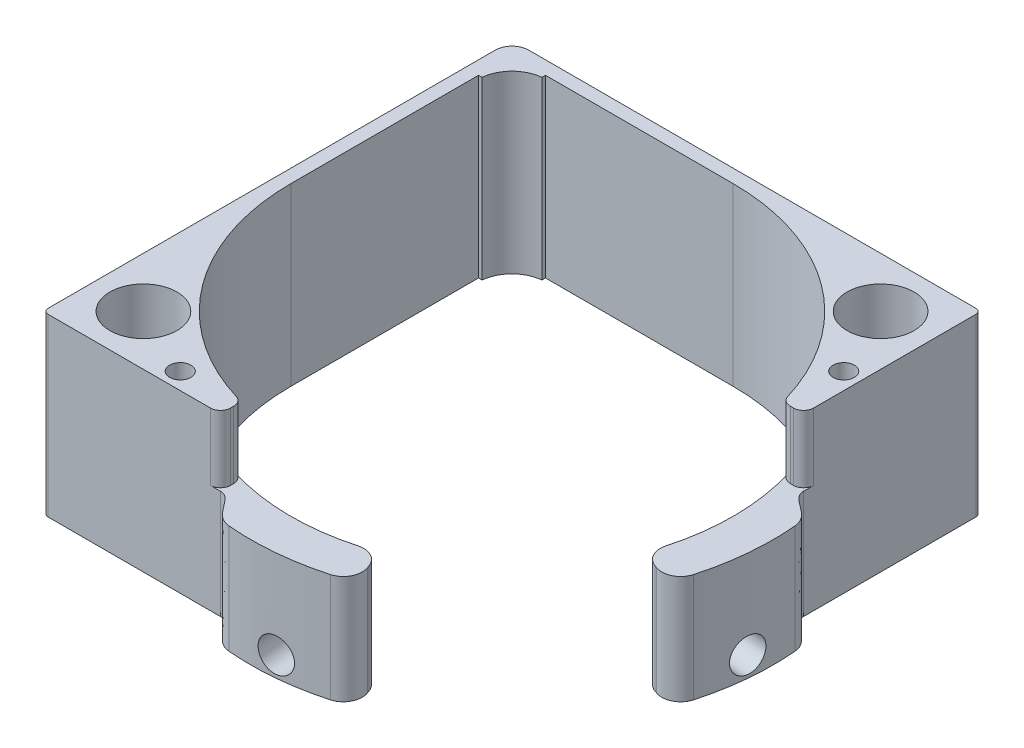
from build123d import *

# Parameters (mm, degrees)
BOSS_EXTRUDE1_DEPTH     = 33.274
SKETCH3_R               = 6.349999999999995
SKETCH3_R_2             = 6.349999999999994
SKETCH3_R_3             = 6.349999999999996
CUT_EXTRUDE1_DEPTH      = 131.05221672851255
BOSS_EXTRUDE2_DEPTH     = 20.574
SKETCH5_R               = 2.0193000000000074
SKETCH5_R_2             = 2.0193000000000025
CUT_EXTRUDE2_DEPTH      = 134.57623111628357
CUT_EXTRUDE3_REACH      = 109.787
CUT_EXTRUDE3_END_RADIUS = 41.90999999999999
SKETCH6_R               = 3.1750000000000003
FILLET1_R               = 3.175
FILLET2_R               = 1.9176999999999997
FILLET3_R               = 1


with BuildPart() as part:
    # Sketch1 → Boss-Extrude1 (new body)
    with BuildSketch(Plane(origin=(0, 0, 0), x_dir=(1, 0, 0), z_dir=(0, 1, 0))):
        with BuildLine():
            Line((0, 0), (33.655, 6.94e-15))
            Line((33.655, 6.94e-15), (33.655, 3.954122740703593))
            ThreePointArc((33.655, 3.954122740703593), (11.216985165351097, 18.91541903613836), (2.5400000000000076, 44.449999999999704))
            Line((2.5400000000000076, 44.449999999999704), (2.540000000000145, 80.00999999999985))
            Line((2.540000000000145, 80.00999999999985), (8.890000000000144, 80.00999999999985))
            Line((8.890000000000144, 80.00999999999985), (8.890000000000148, 86.36))
            Line((8.890000000000148, 86.36), (44.449999999999854, 86.35999999999999))
            ThreePointArc((44.449999999999854, 86.35999999999999), (69.98458096386148, 77.68301483464901), (84.9458772592964, 55.244999999999976))
            Line((84.9458772592964, 55.244999999999976), (88.89999999999999, 55.245))
            Line((88.89999999999999, 55.245), (88.89999999999999, 88.89999999999999))
            Line((88.89999999999999, 88.89999999999999), (0, 88.89999999999999))
            Line((0, 88.89999999999999), (0, 0))
        make_face()
    extrude(amount=BOSS_EXTRUDE1_DEPTH)

    # Sketch3 → Cut-Extrude1 (cut, through all)
    with BuildSketch(Plane(origin=(0, 33.274, 0), x_dir=(1, 0, 0), z_dir=(0, 1, 0))):
        with Locations((9.525000000000004, 79.37499999999999)):
            Circle(SKETCH3_R)
        with Locations(Location((79.375, 79.37499999999999, 0), (0, 0, 270))):
            Circle(SKETCH3_R_2)
        with Locations(Location((9.525000000000006, 9.524999999999991, 0), (0, 0, 270))):
            Circle(SKETCH3_R_3)
    extrude(amount=-CUT_EXTRUDE1_DEPTH, mode=Mode.SUBTRACT)

    # Sketch4 → Boss-Extrude2 (add)
    with BuildSketch(Plane.XZ):
        with BuildLine():
            Line((33.655, -6.94e-15), (33.65499999999999, -3.9541227407036))
            ThreePointArc((33.65499999999999, -3.9541227407036), (44.66502117576741, -2.5405515916282795), (55.65995813673013, -4.067021672829062))
            ThreePointArc((55.65995813673013, -4.067021672829062), (58.23891440878839, -3.8021336224280984), (59.95265305936133, -1.8568107777654739))
            Line((59.95265305936133, -1.8568107777654739), (60.12692723379523, -1.3779964187142884))
            ThreePointArc((60.12692723379523, -1.3779964187142884), (59.94763198470919, 1.464665073241983), (57.73949808555085, 3.263835945500561))
            ThreePointArc((57.73949808555085, 3.263835945500561), (49.009557209614336, 4.869685096848045), (40.13317606170841, 4.89152339648416))
            add(Edge.make_bspline(
                [(33.655, -6.94e-15), (36.19500000000001, -6.94e-15), (36.75939668417103, 4.596355947712086), (40.13317606170841, 4.89152339648416)],
                knots=[0, 0, 0, 0, 1, 1, 1, 1], degree=3))
        make_face()
        with BuildLine():
            Line((87.04318922223452, -28.94734694063866), (87.52200358128572, -28.77307276620477))
            ThreePointArc((87.52200358128572, -28.77307276620477), (90.364665073242, -28.952368015290805), (92.16383594550055, -31.160501914449153))
            ThreePointArc((92.16383594550055, -31.160501914449153), (93.76968509684802, -39.89044279038568), (93.79152339648414, -48.7668239382916))
            add(Edge.make_bspline(
                [(88.89999999999999, -55.245), (88.89999999999999, -52.705), (93.49635594771208, -52.140603315828955), (93.79152339648414, -48.7668239382916)],
                knots=[0, 0, 0, 0, 1, 1, 1, 1], degree=3))
            Line((88.89999999999999, -55.245), (84.9458772592964, -55.245))
            ThreePointArc((84.9458772592964, -55.245), (86.35944840837172, -44.23497882423258), (84.83297832717093, -33.240041863269866))
            ThreePointArc((84.83297832717093, -33.240041863269866), (85.09786637757189, -30.661085591211602), (87.04318922223452, -28.94734694063866))
        make_face()
    extrude(amount=-BOSS_EXTRUDE2_DEPTH)

    # Sketch5 → Cut-Extrude2 (cut, through all)
    with BuildSketch(Plane(origin=(0, 33.274, 0), x_dir=(1, 0, 0), z_dir=(0, 1, 0))):
        with Locations(Location((85.725, 66.03999999999999, 0), (0, 0, 270))):
            Circle(SKETCH5_R)
        with Locations(Location((22.860000000000007, 3.174999999999997, 0), (0, 0, 270))):
            Circle(SKETCH5_R_2)
    extrude(amount=-CUT_EXTRUDE2_DEPTH, mode=Mode.SUBTRACT)

    # Cut-Extrude3: up to this cylinder (the profile starts outside it)
    cut_extrude3_end = Plane(origin=(44.449999999999996, 3.8099999999999987, -44.449999999999996), z_dir=(0, -1, 0)) * Cylinder(CUT_EXTRUDE3_END_RADIUS, 304.394, mode=Mode.PRIVATE)
    # Sketch6 → Cut-Extrude3 (cut, up to the surface)
    with BuildSketch(Plane(origin=(49.00955720961435, 20.573999999999995, 4.869685096848044), x_dir=(0.9957537875398352, 0, -0.0920564750578304), z_dir=(0.0920564750578304, 0, 0.9957537875398352)), mode=Mode.PRIVATE) as cut_extrude3_sk1:
        with Locations((0, -16.763999999999996)):
            Circle(SKETCH6_R)
    cut_extrude3_tool1 = extrude(cut_extrude3_sk1.sketch, amount=-CUT_EXTRUDE3_REACH, mode=Mode.PRIVATE) - cut_extrude3_end
    cut_extrude3 = cut_extrude3_tool1.solids().sort_by_distance((49.009557, 3.81, 4.869685))[0]
    add(cut_extrude3, mode=Mode.SUBTRACT)

    # Mirror1: Cut-Extrude3 across plane
    add(cut_extrude3.mirror(Plane(origin=(44.449999999999996, 0, -44.449999999999996), x_dir=(0.7071067811865477, 0, 0.7071067811865474), z_dir=(-0.7071067811865476, 0, 0.7071067811865476))), mode=Mode.SUBTRACT)

    # Fillet1
    fillet1_edges = [part.edges().sort_by_distance(p)[0] for p in [
        (0, 16.637, -88.89999999999999),
    ]]
    fillet(fillet1_edges, radius=FILLET1_R)

    # Fillet2
    fillet2_edges = [part.edges().sort_by_distance(p)[0] for p in [
        (33.655, 26.924, -3.9541227407035944),
        (33.655, 26.924, -6.94e-15),
        (88.89999999999999, 26.924, -55.245),
        (84.9458772592964, 26.924, -55.244999999999976),
    ]]
    fillet(fillet2_edges, radius=FILLET2_R)

    # Fillet3
    fillet3_edges = [part.edges().sort_by_distance(p)[0] for p in [
        (88.89999999999999, 16.637, -88.89999999999999),
        (0, 16.637, 0),
    ]]
    fillet(fillet3_edges, radius=FILLET3_R)


solid = part.part
